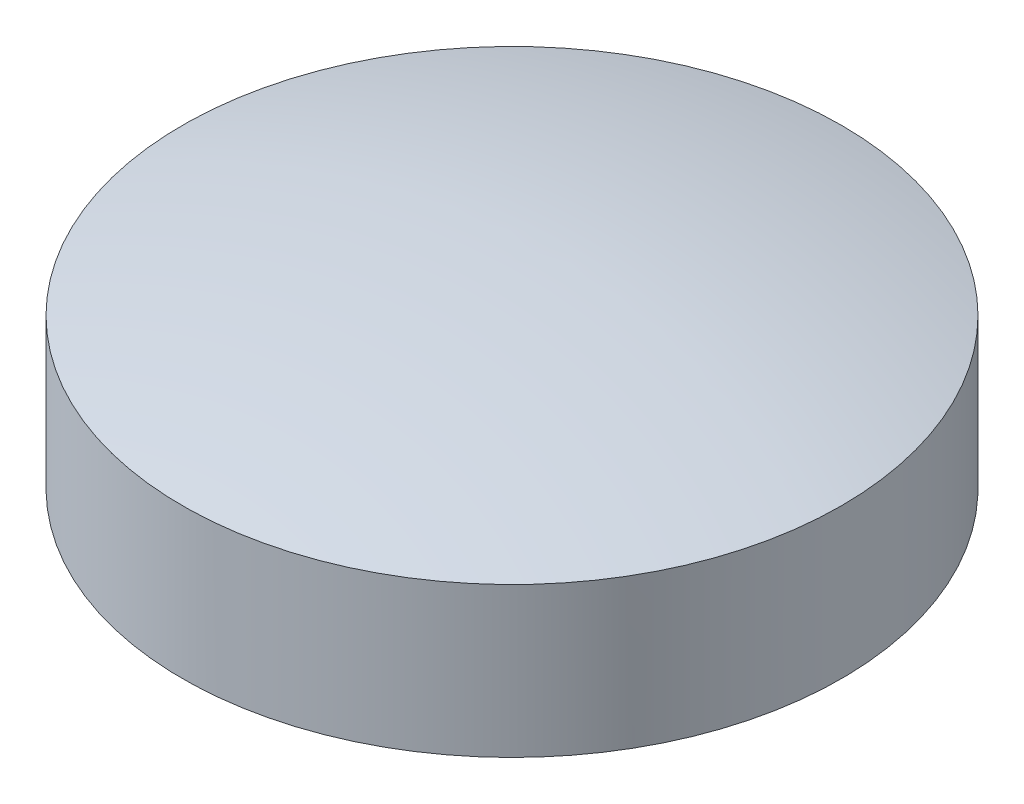
from build123d import *


with BuildPart() as part:
    # Sketch1 → Revolve1 (revolve)
    with BuildSketch(Plane.XY):
        with BuildLine():
            Line((0, 0), (22, 0))
            Line((22, 0), (22, 10))
            ThreePointArc((22, 10), (11.101801656, 12.246545474), (0, 13))
            Line((0, 13), (0, 0))
        make_face()
    revolve(axis=Axis((0, 0, 0), (0, 1, 0)))


solid = part.part
